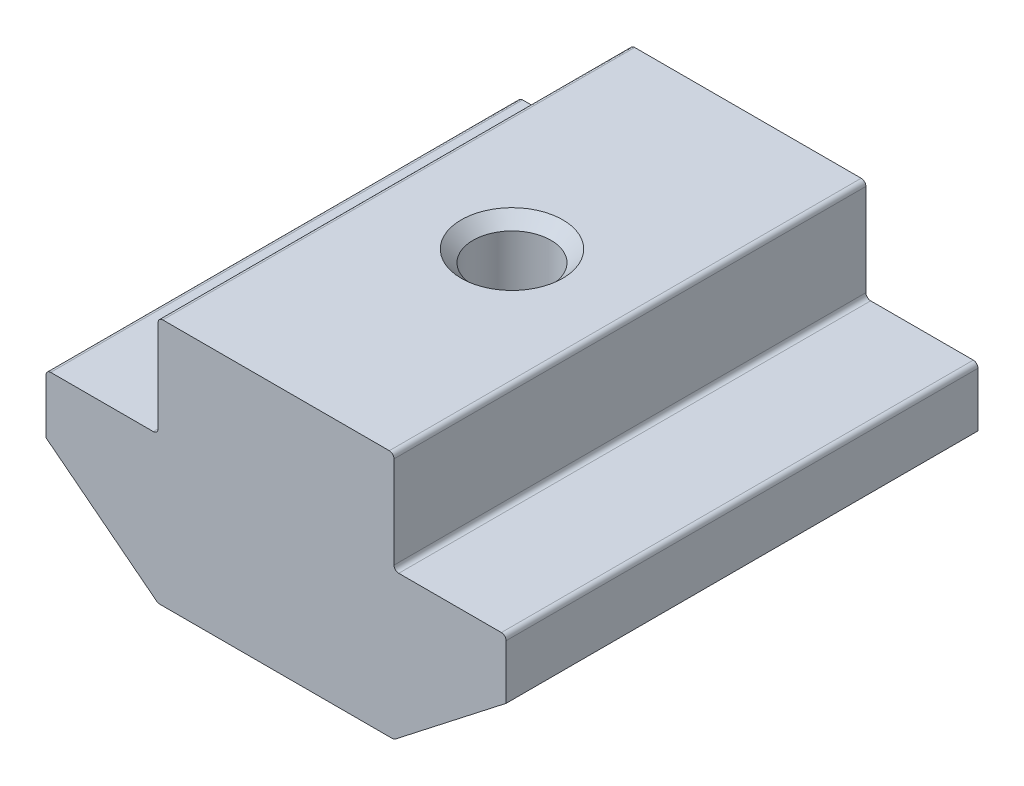
from build123d import *

# Parameters (mm, degrees)
EXTRUDE_1_DEPTH = 10
FILLET_1_R      = 0.2


with BuildPart() as part:
    # Эскиз1 → Бобышка-Вытянуть1 (new body, symmetric)
    with BuildSketch(Plane.XY):
        Polygon((5, 0), (-5, 0), (-5, -4.3), (-9.75, -4.3), (-9.75, -6.8), (-5, -10.5), (5, -10.5), (9.75, -6.8), (9.75, -4.3), (5, -4.3), align=None)
    extrude(amount=EXTRUDE_1_DEPTH, both=True)

    # Эскиз4 → Отверстие обработанное метчиком M44 (revolve, cut)
    with BuildSketch(Plane(origin=(0, 0, 0), x_dir=(0, 0, 1), z_dir=(1, 0, 0))):
        Polygon((0, 0), (0, 10.5), (2.15, 10.5), (1.65, 10), (1.65, 0.5), (2.15, 0), align=None)
    revolve(axis=Axis((0, 6.35, 0), (0, -1, 0)), mode=Mode.SUBTRACT)

    # Скругление1
    fillet_1_edges = [part.edges().sort_by_distance(p)[0] for p in [
        (-5, 0, 0),
        (5, 0, 0),
        (5, -4.3, 0),
        (9.75, -4.3, 0),
        (5, -10.5, 0),
        (-5, -10.5, 0),
        (-9.75, -4.3, 0),
        (-5, -4.3, 0),
    ]]
    fillet(fillet_1_edges, radius=FILLET_1_R)


solid = part.part
